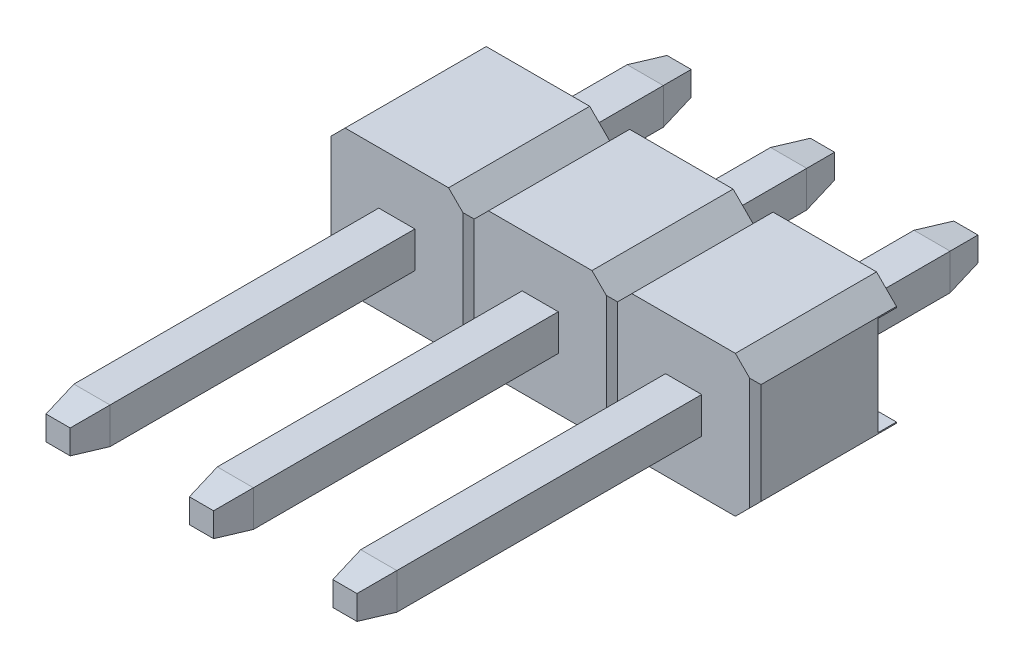
from build123d import *
from OCP.BRepFilletAPI import BRepFilletAPI_MakeChamfer

# Parameters (mm, degrees)
EXTRUDE1_DEPTH          = 1.25
CUT_EXTRUDE3_DEPTH      = 3.176671771
LPATTERN4_COUNT         = 3
LPATTERN4_PITCH         = 2.54
CUT_EXTRUDE1_DEPTH      = 7.591471763
CUT_EXTRUDE1_DEPTH_BACK = 7.591471763
SKETCH2_W               = 1.752893218
SKETCH2_H               = 0.33
SKETCH3_W               = 11
SKETCH3_H               = 0.64
EXTRUDE_THIN1_DEPTH     = 0.32
LPATTERN5_COUNT         = 3
LPATTERN5_PITCH         = 2.54
CHAMFER2_SIZE           = 0.6
CHAMFER2_SIZE2          = 0.105796188


with BuildPart() as part:
    # Sketch1 → Extrude1 (new, symmetric)
    with BuildSketch(Plane.XY):
        Polygon((-1.27, 0.896446609), (-0.916446609, 1.25), (0.916446609, 1.25), (1.27, 0.896446609), (1.27, -0.896446609), (0.916446609, -1.25), (-0.916446609, -1.25), (-1.27, -0.896446609), align=None)
    extrude1 = extrude(amount=EXTRUDE1_DEPTH, both=True)

    # Sketch4 → Cut-Extrude3 (cut, symmetric)
    with BuildSketch(Plane(origin=(0, 0, 0), x_dir=(1, 0, 0), z_dir=(0, 1, 0))):
        Polygon((-1.27, -1.15), (-1.17, -1.25), (-1.27, -1.25), align=None)
        Polygon((1.17, -1.25), (1.27, -1.15), (1.27, -1.25), align=None)
    cut_extrude3 = extrude(amount=CUT_EXTRUDE3_DEPTH, both=True, mode=Mode.SUBTRACT)

    # LPattern4: Extrude1, Cut-Extrude3 ×3
    with Locations(*[(-i * LPATTERN4_PITCH, 0, 0) for i in range(1, LPATTERN4_COUNT)]):
        add(extrude1)
        add(cut_extrude3, mode=Mode.SUBTRACT)

    # Sketch2 → Cut-Extrude1 (cut, two sides: drawn at the far end of the back side and taken through both)
    with BuildSketch(Plane(origin=(0, 0, 0), x_dir=(0, -1, 0), z_dir=(1, 0, 0)).offset(-CUT_EXTRUDE1_DEPTH_BACK)):
        with Locations((0, 1.085)):
            Rectangle(SKETCH2_W, SKETCH2_H)
    extrude(amount=CUT_EXTRUDE1_DEPTH + CUT_EXTRUDE1_DEPTH_BACK, mode=Mode.SUBTRACT)

    # Sketch3 → Extrude-Thin1 (add, symmetric)
    with BuildSketch(Plane(origin=(0, 0, 0), x_dir=(0, 0, -1), z_dir=(1, 0, 0))):
        with Locations((-1.75, 0)):
            Rectangle(SKETCH3_W, SKETCH3_H)
    extrude_thin1 = extrude(amount=EXTRUDE_THIN1_DEPTH, both=True)

    # LPattern5: Extrude-Thin1 ×3
    with Locations(*[(-i * LPATTERN5_PITCH, 0, 0) for i in range(1, LPATTERN5_COUNT)]):
        add(extrude_thin1)

    # Chamfer2: one chamfer whose edges measure the first distance from different faces: ONE call of the kernel's chamfer builder (chamfer() names one face for all edges)
    chamfer2_edges_1 = [part.edges().sort_by_distance(p)[0] for p in [
        (0.32, 0, 7.25),
    ]]
    chamfer2_side_1 = [part.faces().sort_by_distance(p)[0] for p in [
        (0.32, 0, 4.25),
    ]]
    chamfer2_edges_2 = [part.edges().sort_by_distance(p)[0] for p in [
        (0, -0.32, 7.25),
    ]]
    chamfer2_side_2 = [part.faces().sort_by_distance(p)[0] for p in [
        (0, -0.32, 4.25),
    ]]
    chamfer2_edges_3 = [part.edges().sort_by_distance(p)[0] for p in [
        (-0.32, 0, 7.25),
    ]]
    chamfer2_side_3 = [part.faces().sort_by_distance(p)[0] for p in [
        (-0.32, 0, 4.25),
    ]]
    chamfer2_edges_4 = [part.edges().sort_by_distance(p)[0] for p in [
        (0, 0.32, 7.25),
    ]]
    chamfer2_side_4 = [part.faces().sort_by_distance(p)[0] for p in [
        (0, 0.32, 4.25),
    ]]
    chamfer2_edges_5 = [part.edges().sort_by_distance(p)[0] for p in [
        (0.32, 0, -3.75),
    ]]
    chamfer2_side_5 = [part.faces().sort_by_distance(p)[0] for p in [
        (0.32, 0, -2.335),
    ]]
    chamfer2_edges_6 = [part.edges().sort_by_distance(p)[0] for p in [
        (-0.32, 0, -3.75),
    ]]
    chamfer2_side_6 = [part.faces().sort_by_distance(p)[0] for p in [
        (-0.32, 0, -2.335),
    ]]
    chamfer2_edges_7 = [part.edges().sort_by_distance(p)[0] for p in [
        (-4.76, 0, -3.75),
    ]]
    chamfer2_side_7 = [part.faces().sort_by_distance(p)[0] for p in [
        (-4.76, 0, -2.335),
    ]]
    chamfer2_edges_8 = [part.edges().sort_by_distance(p)[0] for p in [
        (-5.4, 0, -3.75),
    ]]
    chamfer2_side_8 = [part.faces().sort_by_distance(p)[0] for p in [
        (-5.4, 0, -2.335),
    ]]
    chamfer2_edges_9 = [part.edges().sort_by_distance(p)[0] for p in [
        (-2.22, 0, -3.75),
    ]]
    chamfer2_side_9 = [part.faces().sort_by_distance(p)[0] for p in [
        (-2.22, 0, -2.335),
    ]]
    chamfer2_edges_10 = [part.edges().sort_by_distance(p)[0] for p in [
        (-2.86, 0, -3.75),
    ]]
    chamfer2_side_10 = [part.faces().sort_by_distance(p)[0] for p in [
        (-2.86, 0, -2.335),
    ]]
    chamfer2_edges_11 = [part.edges().sort_by_distance(p)[0] for p in [
        (-2.22, 0, 7.25),
    ]]
    chamfer2_side_11 = [part.faces().sort_by_distance(p)[0] for p in [
        (-2.22, 0, 4.25),
    ]]
    chamfer2_edges_12 = [part.edges().sort_by_distance(p)[0] for p in [
        (-2.54, -0.32, 7.25),
    ]]
    chamfer2_side_12 = [part.faces().sort_by_distance(p)[0] for p in [
        (-2.54, -0.32, 4.25),
    ]]
    chamfer2_edges_13 = [part.edges().sort_by_distance(p)[0] for p in [
        (-2.86, 0, 7.25),
    ]]
    chamfer2_side_13 = [part.faces().sort_by_distance(p)[0] for p in [
        (-2.86, 0, 4.25),
    ]]
    chamfer2_edges_14 = [part.edges().sort_by_distance(p)[0] for p in [
        (-2.54, 0.32, 7.25),
    ]]
    chamfer2_side_14 = [part.faces().sort_by_distance(p)[0] for p in [
        (-2.54, 0.32, 4.25),
    ]]
    chamfer2_edges_15 = [part.edges().sort_by_distance(p)[0] for p in [
        (-4.76, 0, 7.25),
    ]]
    chamfer2_side_15 = [part.faces().sort_by_distance(p)[0] for p in [
        (-4.76, 0, 4.25),
    ]]
    chamfer2_edges_16 = [part.edges().sort_by_distance(p)[0] for p in [
        (-5.08, -0.32, 7.25),
    ]]
    chamfer2_side_16 = [part.faces().sort_by_distance(p)[0] for p in [
        (-5.08, -0.32, 4.25),
    ]]
    chamfer2_edges_17 = [part.edges().sort_by_distance(p)[0] for p in [
        (-5.4, 0, 7.25),
    ]]
    chamfer2_side_17 = [part.faces().sort_by_distance(p)[0] for p in [
        (-5.4, 0, 4.25),
    ]]
    chamfer2_edges_18 = [part.edges().sort_by_distance(p)[0] for p in [
        (-5.08, 0.32, 7.25),
    ]]
    chamfer2_side_18 = [part.faces().sort_by_distance(p)[0] for p in [
        (-5.08, 0.32, 4.25),
    ]]
    chamfer2_edges_19 = [part.edges().sort_by_distance(p)[0] for p in [
        (-2.54, 0.32, -3.75),
    ]]
    chamfer2_side_19 = [part.faces().sort_by_distance(p)[0] for p in [
        (-2.54, 0.32, -2.335),
    ]]
    chamfer2_edges_20 = [part.edges().sort_by_distance(p)[0] for p in [
        (-2.54, -0.32, -3.75),
    ]]
    chamfer2_side_20 = [part.faces().sort_by_distance(p)[0] for p in [
        (-2.54, -0.32, -2.335),
    ]]
    chamfer2_edges_21 = [part.edges().sort_by_distance(p)[0] for p in [
        (0, 0.32, -3.75),
    ]]
    chamfer2_side_21 = [part.faces().sort_by_distance(p)[0] for p in [
        (0, 0.32, -2.335),
    ]]
    chamfer2_edges_22 = [part.edges().sort_by_distance(p)[0] for p in [
        (0, -0.32, -3.75),
    ]]
    chamfer2_side_22 = [part.faces().sort_by_distance(p)[0] for p in [
        (0, -0.32, -2.335),
    ]]
    chamfer2_edges_23 = [part.edges().sort_by_distance(p)[0] for p in [
        (-5.08, 0.32, -3.75),
    ]]
    chamfer2_side_23 = [part.faces().sort_by_distance(p)[0] for p in [
        (-5.08, 0.32, -2.335),
    ]]
    chamfer2_edges_24 = [part.edges().sort_by_distance(p)[0] for p in [
        (-5.08, -0.32, -3.75),
    ]]
    chamfer2_side_24 = [part.faces().sort_by_distance(p)[0] for p in [
        (-5.08, -0.32, -2.335),
    ]]
    chamfer2 = BRepFilletAPI_MakeChamfer(part.part.solid().wrapped)
    for e in chamfer2_edges_1:
        chamfer2.Add(CHAMFER2_SIZE, CHAMFER2_SIZE2, e.wrapped, chamfer2_side_1[0].wrapped)  # the first distance lies on this face
    for e in chamfer2_edges_2:
        chamfer2.Add(CHAMFER2_SIZE, CHAMFER2_SIZE2, e.wrapped, chamfer2_side_2[0].wrapped)  # the first distance lies on this face
    for e in chamfer2_edges_3:
        chamfer2.Add(CHAMFER2_SIZE, CHAMFER2_SIZE2, e.wrapped, chamfer2_side_3[0].wrapped)  # the first distance lies on this face
    for e in chamfer2_edges_4:
        chamfer2.Add(CHAMFER2_SIZE, CHAMFER2_SIZE2, e.wrapped, chamfer2_side_4[0].wrapped)  # the first distance lies on this face
    for e in chamfer2_edges_5:
        chamfer2.Add(CHAMFER2_SIZE, CHAMFER2_SIZE2, e.wrapped, chamfer2_side_5[0].wrapped)  # the first distance lies on this face
    for e in chamfer2_edges_6:
        chamfer2.Add(CHAMFER2_SIZE, CHAMFER2_SIZE2, e.wrapped, chamfer2_side_6[0].wrapped)  # the first distance lies on this face
    for e in chamfer2_edges_7:
        chamfer2.Add(CHAMFER2_SIZE, CHAMFER2_SIZE2, e.wrapped, chamfer2_side_7[0].wrapped)  # the first distance lies on this face
    for e in chamfer2_edges_8:
        chamfer2.Add(CHAMFER2_SIZE, CHAMFER2_SIZE2, e.wrapped, chamfer2_side_8[0].wrapped)  # the first distance lies on this face
    for e in chamfer2_edges_9:
        chamfer2.Add(CHAMFER2_SIZE, CHAMFER2_SIZE2, e.wrapped, chamfer2_side_9[0].wrapped)  # the first distance lies on this face
    for e in chamfer2_edges_10:
        chamfer2.Add(CHAMFER2_SIZE, CHAMFER2_SIZE2, e.wrapped, chamfer2_side_10[0].wrapped)  # the first distance lies on this face
    for e in chamfer2_edges_11:
        chamfer2.Add(CHAMFER2_SIZE, CHAMFER2_SIZE2, e.wrapped, chamfer2_side_11[0].wrapped)  # the first distance lies on this face
    for e in chamfer2_edges_12:
        chamfer2.Add(CHAMFER2_SIZE, CHAMFER2_SIZE2, e.wrapped, chamfer2_side_12[0].wrapped)  # the first distance lies on this face
    for e in chamfer2_edges_13:
        chamfer2.Add(CHAMFER2_SIZE, CHAMFER2_SIZE2, e.wrapped, chamfer2_side_13[0].wrapped)  # the first distance lies on this face
    for e in chamfer2_edges_14:
        chamfer2.Add(CHAMFER2_SIZE, CHAMFER2_SIZE2, e.wrapped, chamfer2_side_14[0].wrapped)  # the first distance lies on this face
    for e in chamfer2_edges_15:
        chamfer2.Add(CHAMFER2_SIZE, CHAMFER2_SIZE2, e.wrapped, chamfer2_side_15[0].wrapped)  # the first distance lies on this face
    for e in chamfer2_edges_16:
        chamfer2.Add(CHAMFER2_SIZE, CHAMFER2_SIZE2, e.wrapped, chamfer2_side_16[0].wrapped)  # the first distance lies on this face
    for e in chamfer2_edges_17:
        chamfer2.Add(CHAMFER2_SIZE, CHAMFER2_SIZE2, e.wrapped, chamfer2_side_17[0].wrapped)  # the first distance lies on this face
    for e in chamfer2_edges_18:
        chamfer2.Add(CHAMFER2_SIZE, CHAMFER2_SIZE2, e.wrapped, chamfer2_side_18[0].wrapped)  # the first distance lies on this face
    for e in chamfer2_edges_19:
        chamfer2.Add(CHAMFER2_SIZE, CHAMFER2_SIZE2, e.wrapped, chamfer2_side_19[0].wrapped)  # the first distance lies on this face
    for e in chamfer2_edges_20:
        chamfer2.Add(CHAMFER2_SIZE, CHAMFER2_SIZE2, e.wrapped, chamfer2_side_20[0].wrapped)  # the first distance lies on this face
    for e in chamfer2_edges_21:
        chamfer2.Add(CHAMFER2_SIZE, CHAMFER2_SIZE2, e.wrapped, chamfer2_side_21[0].wrapped)  # the first distance lies on this face
    for e in chamfer2_edges_22:
        chamfer2.Add(CHAMFER2_SIZE, CHAMFER2_SIZE2, e.wrapped, chamfer2_side_22[0].wrapped)  # the first distance lies on this face
    for e in chamfer2_edges_23:
        chamfer2.Add(CHAMFER2_SIZE, CHAMFER2_SIZE2, e.wrapped, chamfer2_side_23[0].wrapped)  # the first distance lies on this face
    for e in chamfer2_edges_24:
        chamfer2.Add(CHAMFER2_SIZE, CHAMFER2_SIZE2, e.wrapped, chamfer2_side_24[0].wrapped)  # the first distance lies on this face
    add(Compound.cast(chamfer2.Shape()), mode=Mode.REPLACE)


solid = part.part
